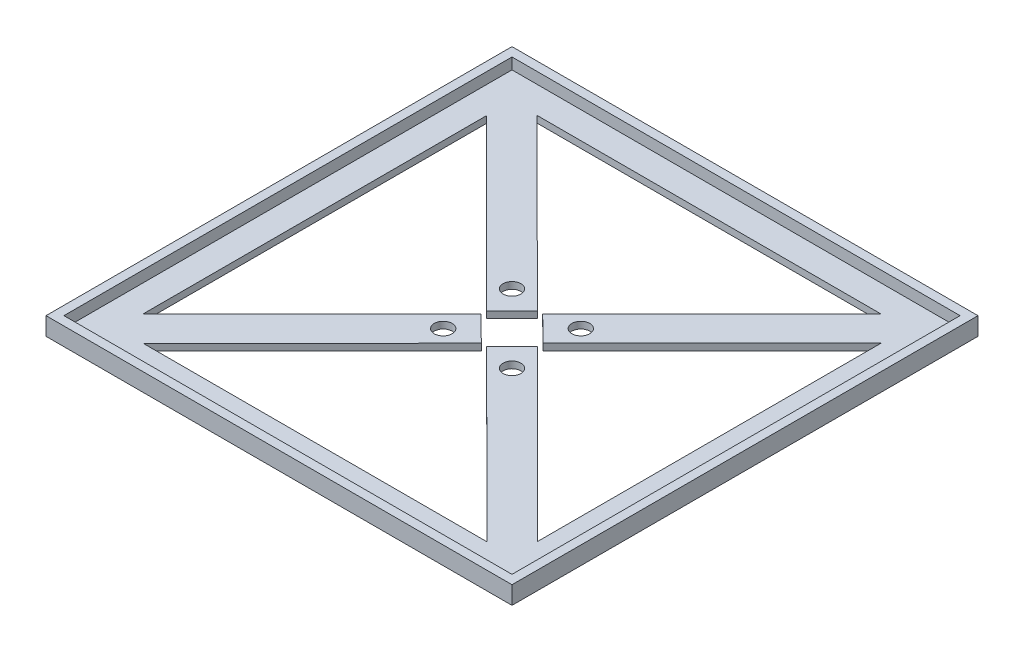
from build123d import *

# Parameters (mm, degrees)
SKETCH1_W           = 50
SKETCH1_H           = 50
SKETCH1_W_2         = 44
SKETCH1_H_2         = 44
EXTRUDE_THIN1_DEPTH = 0.75
SKETCH1_3_R         = 1
BOSS_EXTRUDE1_DEPTH = 0.75
SKETCH1_4_W         = 52
SKETCH1_4_H         = 52
SKETCH1_4_W_2       = 50
SKETCH1_4_H_2       = 50
EXTRUDE_THIN2_DEPTH = 2


with BuildPart() as part:
    # Sketch1 → Extrude-Thin1 (new body)
    with BuildSketch(Plane(origin=(0, 0, 0), x_dir=(1, 0, 0), z_dir=(0, 1, 0))):
        with Locations((-6.298946979, 2.1638593)):
            Rectangle(SKETCH1_W, SKETCH1_H)
        with Locations((-6.298946979, 2.1638593)):
            Rectangle(SKETCH1_W_2, SKETCH1_H_2, mode=Mode.SUBTRACT)
    extrude(amount=EXTRUDE_THIN1_DEPTH)

    # Sketch1_3 → Boss-Extrude1 (add)
    # profile 1 of 4: a face of its own
    with BuildSketch(Plane(origin=(0, 0, 0), x_dir=(1, 0, 0), z_dir=(0, 1, 0))):
        Polygon((-9.430665417, 1.860567093), (-31.298946979, -20.042512046), (-31.298946979, -22.8361407), (-28.435774882, -22.8361407), (-6.59999063, -0.965610581), align=None)
        with Locations((-10.136648367, -1.673842088)):
            Circle(SKETCH1_3_R, mode=Mode.SUBTRACT)
    # profile 2 of 4: a face of its own
    with BuildSketch(Plane(origin=(0, 0, 0), x_dir=(1, 0, 0), z_dir=(0, 1, 0))):
        Polygon((-5.995654771, -0.967859138), (15.907424367, -22.8361407), (18.701053021, -22.8361407), (18.701053021, -19.972968602), (-3.169477097, 1.86281565), align=None)
        with Locations((-2.461245591, -1.673842088)):
            Circle(SKETCH1_3_R, mode=Mode.SUBTRACT)
    # profile 3 of 4: a face of its own
    with BuildSketch(Plane(origin=(0, 0, 0), x_dir=(1, 0, 0), z_dir=(0, 1, 0))):
        Polygon((18.701053021, 27.1638593), (15.837880924, 27.1638593), (-5.997903328, 5.293329182), (-3.167228541, 2.467151508), (18.701053021, 24.370230647), align=None)
        with Locations((-2.461245591, 6.001560689)):
            Circle(SKETCH1_3_R, mode=Mode.SUBTRACT)
    # profile 4 of 4: a face of its own
    with BuildSketch(Plane(origin=(0, 0, 0), x_dir=(1, 0, 0), z_dir=(0, 1, 0))):
        Polygon((-31.298946979, 27.1638593), (-31.298946979, 24.300687203), (-9.428416861, 2.464902951), (-6.602239187, 5.295577739), (-28.505318325, 27.1638593), align=None)
        with Locations((-10.136648367, 6.001560689)):
            Circle(SKETCH1_3_R, mode=Mode.SUBTRACT)
    extrude(amount=BOSS_EXTRUDE1_DEPTH)

    # Sketch1_4 → Extrude-Thin2 (add)
    with BuildSketch(Plane(origin=(0, 0, 0), x_dir=(1, 0, 0), z_dir=(0, 1, 0))):
        with Locations((-6.298946979, 2.1638593)):
            Rectangle(SKETCH1_4_W, SKETCH1_4_H)
        with Locations((-6.298946979, 2.1638593)):
            Rectangle(SKETCH1_4_W_2, SKETCH1_4_H_2, mode=Mode.SUBTRACT)
    extrude(amount=EXTRUDE_THIN2_DEPTH)


solid = part.part
